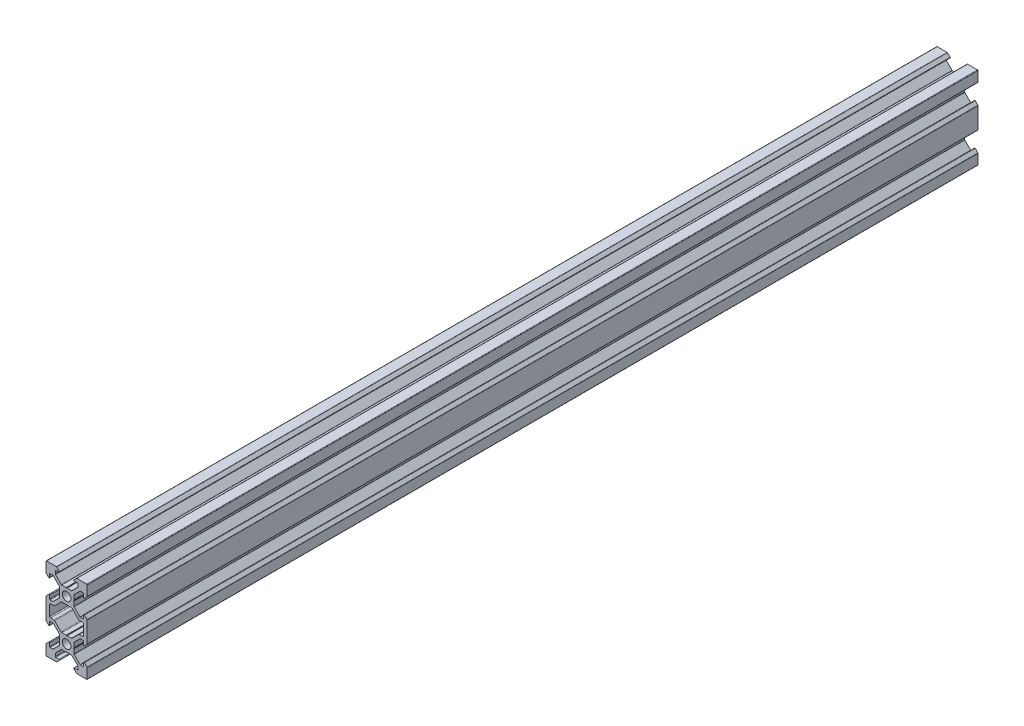
from build123d import *

# Parameters (mm, degrees)
SKETCH1_R           = 2.1
BOSS_EXTRUDE1_DEPTH = 432
FILLET1_R           = 0.25
FILLET2_R           = 0.5
CUT_EXTRUDE1_DEPTH  = 433


with BuildPart() as part:
    # Sketch1 → Boss-Extrude1 (new body)
    with BuildSketch(Plane.XY):
        Polygon((3.560660172, -2.5), (3.560660172, 2.5), (6.560660172, 5.5), (8.252142372, 5.5), (8.252142372, 3.1), (10, 4.847857628), (10, 10), (4.847857628, 10), (3.1, 8.252142372), (5.5, 8.252142372), (5.5, 6.560660172), (2.5, 3.560660172), (-2.5, 3.560660172), (-5.5, 6.560660172), (-5.5, 8.252142372), (-3.1, 8.252142372), (-4.847857628, 10), (-10, 10), (-10, 4.847857628), (-8.252142372, 3.1), (-8.252142372, 5.5), (-6.560660172, 5.5), (-3.560660172, 2.5), (-3.560660172, -2.5), (-6.560660172, -5.5), (-8.252142372, -5.5), (-8.252142372, -3.1), (-10, -4.847857628), (-10, -7), (-10, -13), (-10, -15.152142372), (-8.252142372, -16.9), (-8.252142372, -14.5), (-6.560660172, -14.5), (-3.560660172, -17.5), (-3.560660172, -22.5), (-6.560660172, -25.5), (-8.252142372, -25.5), (-8.252142372, -23.1), (-10, -24.847857628), (-10, -30), (-4.847857628, -30), (-3.1, -28.252142372), (-5.5, -28.252142372), (-5.5, -26.560660172), (-2.5, -23.560660172), (2.5, -23.560660172), (5.5, -26.560660172), (5.5, -28.252142372), (3.1, -28.252142372), (4.847857628, -30), (10, -30), (10, -24.847857628), (8.252142372, -23.1), (8.252142372, -25.5), (6.560660172, -25.5), (3.560660172, -22.5), (3.560660172, -17.5), (6.560660172, -14.5), (8.252142372, -14.5), (8.252142372, -16.9), (10, -15.152142372), (10, -13), (10, -7), (10, -4.847857628), (8.252142372, -3.1), (8.252142372, -5.5), (6.560660172, -5.5), align=None)
        Circle(SKETCH1_R, mode=Mode.SUBTRACT)
        with Locations((0, -20)):
            Circle(SKETCH1_R, mode=Mode.SUBTRACT)
        Polygon((2.5, -3.560660172), (-2.5, -3.560660172), (-5.5, -6.560660172), (-5.939339828, -7), (-8.252142372, -7), (-8.252142372, -13), (-5.939339828, -13), (-5.5, -13.439339828), (-2.5, -16.439339828), (2.5, -16.439339828), (5.5, -13.439339828), (5.939339828, -13), (8.252142372, -13), (8.252142372, -7), (5.939339828, -7), (5.5, -6.560660172), align=None, mode=Mode.SUBTRACT)
    extrude(amount=BOSS_EXTRUDE1_DEPTH)

    # Fillet1
    fillet1_edges = [part.edges().sort_by_distance(p)[0] for p in [
        (5.5, 6.560660172, 216),
        (5.5, 8.252142372, 216),
        (3.1, 8.252142372, 216),
        (4.847857628, 10, 216),
        (10, 10, 216),
        (10, 4.847857628, 216),
        (8.252142372, 3.1, 216),
        (8.252142372, 5.5, 216),
        (6.560660172, 5.5, 216),
        (3.560660172, 2.5, 216),
        (3.560660172, -2.5, 216),
        (6.560660172, -5.5, 216),
        (8.252142372, -5.5, 216),
        (8.252142372, -3.1, 216),
        (10, -4.847857628, 216),
        (10, -15.152142372, 216),
        (8.252142372, -16.9, 216),
        (8.252142372, -14.5, 216),
        (6.560660172, -14.5, 216),
        (3.560660172, -17.5, 216),
        (3.560660172, -22.5, 216),
        (6.560660172, -25.5, 216),
        (8.252142372, -25.5, 216),
        (8.252142372, -23.1, 216),
        (10, -24.847857628, 216),
        (10, -30, 216),
        (4.847857628, -30, 216),
        (3.1, -28.252142372, 216),
        (5.5, -28.252142372, 216),
        (5.5, -26.560660172, 216),
        (2.5, -23.560660172, 216),
        (-2.5, -23.560660172, 216),
        (-5.5, -26.560660172, 216),
        (-5.5, -28.252142372, 216),
        (-3.1, -28.252142372, 216),
        (-4.847857628, -30, 216),
        (-10, -30, 216),
        (-10, -24.847857628, 216),
        (-8.252142372, -23.1, 216),
        (-8.252142372, -25.5, 216),
        (-6.560660172, -25.5, 216),
        (-3.560660172, -22.5, 216),
        (-3.560660172, -17.5, 216),
        (-6.560660172, -14.5, 216),
        (-8.252142372, -14.5, 216),
        (-8.252142372, -16.9, 216),
        (-10, -15.152142372, 216),
        (-10, -4.847857628, 216),
        (-8.252142372, -3.1, 216),
        (-8.252142372, -5.5, 216),
        (-6.560660172, -5.5, 216),
        (-3.560660172, -2.5, 216),
        (-3.560660172, 2.5, 216),
        (-6.560660172, 5.5, 216),
        (-8.252142372, 5.5, 216),
        (-8.252142372, 3.1, 216),
        (-10, 4.847857628, 216),
        (-10, 10, 216),
        (-4.847857628, 10, 216),
        (-3.1, 8.252142372, 216),
        (-5.5, 8.252142372, 216),
        (-5.5, 6.560660172, 216),
        (-2.5, 3.560660172, 216),
        (2.5, 3.560660172, 216),
    ]]
    fillet(fillet1_edges, radius=FILLET1_R)

    # Fillet2
    fillet2_edges = [part.edges().sort_by_distance(p)[0] for p in [
        (-2.5, -3.560660172, 216),
        (-5.939339828, -7, 216),
        (-8.252142372, -7, 216),
        (-8.252142372, -13, 216),
        (-5.939339828, -13, 216),
        (-2.5, -16.439339828, 216),
        (2.5, -16.439339828, 216),
        (5.939339828, -13, 216),
        (8.252142372, -13, 216),
        (8.252142372, -7, 216),
        (5.939339828, -7, 216),
        (2.5, -3.560660172, 216),
    ]]
    fillet(fillet2_edges, radius=FILLET2_R)

    # Sketch2 → Cut-Extrude1 (cut, through all)
    with BuildSketch(Plane.XY.offset(432)):
        Polygon((0, 3.398953432), (-0.242280927, 3.560660172), (0.242280927, 3.560660172), align=None)
        Polygon((0, -3.398953432), (0.242280927, -3.560660172), (-0.242280927, -3.560660172), align=None)
        Polygon((3.560660172, 0.242280927), (3.560660172, -0.242280927), (3.398953432, 0), align=None)
        Polygon((-3.560660172, 0.242280927), (-3.560660172, -0.242280927), (-3.398953432, 0), align=None)
        Polygon((-3.398953432, -20), (-3.560660172, -20.242280927), (-3.560660172, -19.757719073), align=None)
        Polygon((3.398953432, -20), (3.560660172, -19.757719073), (3.560660172, -20.242280927), align=None)
        Polygon((-0.242280927, -16.439339828), (0.242280927, -16.439339828), (0, -16.601046568), align=None)
        Polygon((-0.242280927, -23.560660172), (0.242280927, -23.560660172), (0, -23.398953432), align=None)
    extrude(amount=-CUT_EXTRUDE1_DEPTH, mode=Mode.SUBTRACT)


solid = part.part
